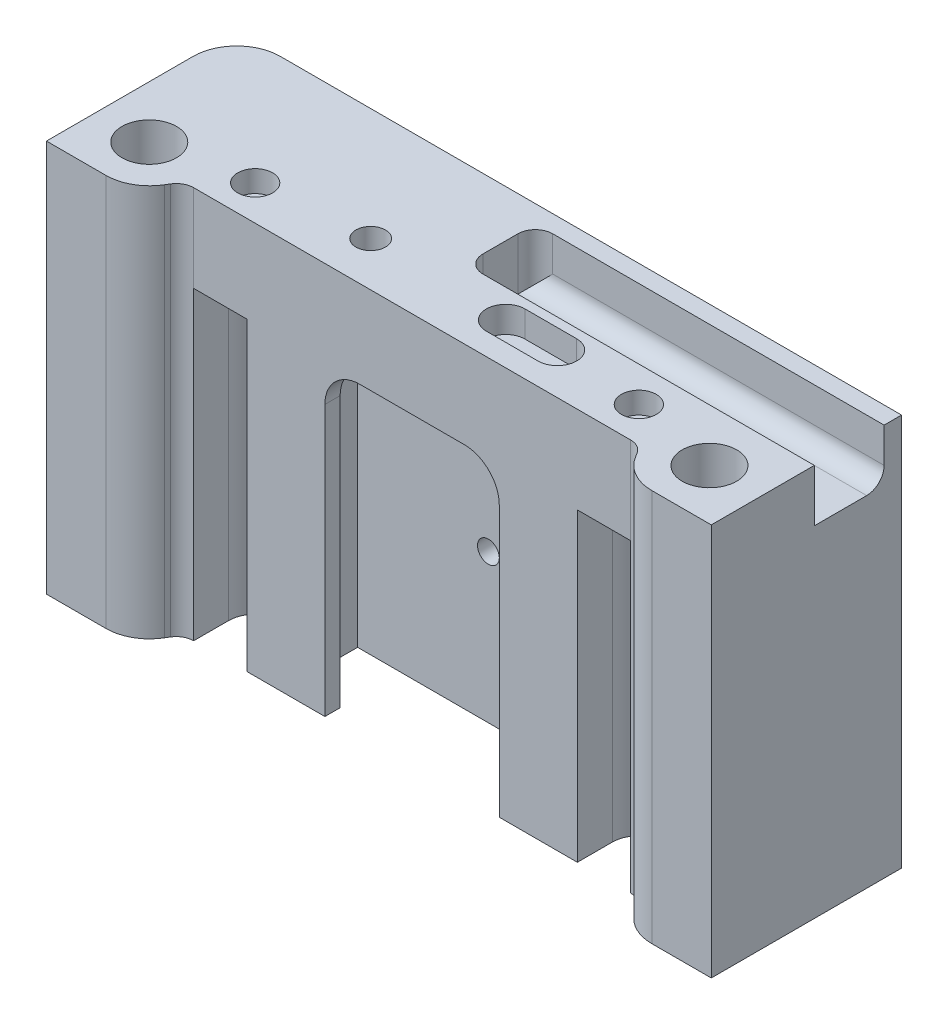
from build123d import *

# Parameters (mm, degrees)
SKETCH1_R                       = 2
SKETCH1_R_2                     = 3.125
SKETCH1_R_3                     = 1.7
BOSS_EXTRUDE1_DEPTH             = 10
FILLET2_R                       = 5
FILLET1_R                       = 2
SKETCH1_4_R                     = 3.125
CUT_EXTRUDE3_DEPTH              = 5.07
SKETCH1_7_R                     = 1.7
CUT_EXTRUDE6_DEPTH              = 10
CUT_EXTRUDE5_DEPTH              = 3
SKETCH1_5_R                     = 2
CUT_EXTRUDE4_DEPTH              = 2.48
SKETCH4_R                       = 1.5
CUT_EXTRUDE7_DEPTH              = 10
SKETCH5_R                       = 2.725
CUT_EXTRUDE8_DEPTH              = 2.8
BOSS_EXTRUDE2_DEPTH             = 10
BOSS_EXTRUDE3_DEPTH             = 35
FILLET13_R                      = 5
SKETCH10_W                      = 8
SKETCH10_H                      = 6
CUT_EXTRUDE12_DEPTH             = 40
FILLET14_R                      = 2
CUT_EXTRUDE17_DEPTH             = 35
TAP_DRILL_FOR_M3X0_5_TAP1_D     = 2.5
TAP_DRILL_FOR_M3X0_5_TAP1_DEPTH = 4.248924226
TAP_DRILL_FOR_M3X0_5_TAP1_TIP   = 0.751075774
SKETCH23_2_R                    = 3.25
BOSS_EXTRUDE7_DEPTH             = 2
FILLET16_R                      = 4
SKETCH23_R                      = 3.25
CUT_EXTRUDE20_DEPTH             = 10
CUT_EXTRUDE20_DEPTH_BACK        = 4


with BuildPart() as part:
    # Sketch1 → Boss-Extrude1 (new body)
    with BuildSketch(Plane(origin=(0, 0, 0), x_dir=(1, 0, 0), z_dir=(0, 1, 0))):
        with BuildLine():
            ThreePointArc((-11.409245094, 8.977987014), (-9.849239736, 9.28), (-8.289234378, 8.977987014))
            ThreePointArc((-8.289234378, 8.977987014), (-5.835653376, 8.254222737), (-3.289234378, 8.01))
            Line((-3.289234378, 8.01), (38.12, 8.01))
            Line((38.12, 8.01), (38.12, -3.81))
            Line((38.12, -3.81), (28.478275237, -3.81))
            Line((28.478275237, -3.81), (26.178275237, 0))
            Line((26.178275237, 0), (-26.178275237, 0))
            Line((-26.178275237, 0), (-28.478275237, -3.81))
            Line((-28.478275237, -3.81), (-38.12, -3.81))
            Line((-38.12, -3.81), (-38.12, 8.01))
            Line((-38.12, 8.01), (-16.409245094, 8.01))
            ThreePointArc((-16.409245094, 8.01), (-13.862826096, 8.254222737), (-11.409245094, 8.977987014))
        make_face()
        with Locations((22, 4.005)):
            Circle(SKETCH1_R, mode=Mode.SUBTRACT)
        with Locations((-22, 4.005)):
            Circle(SKETCH1_R, mode=Mode.SUBTRACT)
        with Locations((-32.12, 1.98)):
            Circle(SKETCH1_R_2, mode=Mode.SUBTRACT)
        with Locations((32.12, 1.98)):
            Circle(SKETCH1_R_2, mode=Mode.SUBTRACT)
        with Locations((-9.849239736, 5.1)):
            Circle(SKETCH1_R_3, mode=Mode.SUBTRACT)
        with BuildLine():
            ThreePointArc((11.912105026, 2.53), (14.127105026, 4.745), (11.912105026, 6.96))
            Line((11.912105026, 6.96), (5.992105026, 6.96))
            ThreePointArc((5.992105026, 6.96), (3.777105026, 4.745), (5.992105026, 2.53))
            Line((5.992105026, 2.53), (11.912105026, 2.53))
        make_face(mode=Mode.SUBTRACT)
        with Locations((-22, 4.005)):
            Circle(SKETCH1_R)
        with Locations((-9.849239736, 5.1)):
            Circle(SKETCH1_R_3)
        with Locations((-32.12, 1.98)):
            Circle(SKETCH1_R_2)
        with BuildLine():
            Line((5.992105026, 2.53), (11.912105026, 2.53))
            ThreePointArc((11.912105026, 2.53), (14.127105026, 4.745), (11.912105026, 6.96))
            Line((11.912105026, 6.96), (5.992105026, 6.96))
            ThreePointArc((5.992105026, 6.96), (3.777105026, 4.745), (5.992105026, 2.53))
        make_face()
        with Locations((22, 4.005)):
            Circle(SKETCH1_R)
        with Locations((32.12, 1.98)):
            Circle(SKETCH1_R_2)
    extrude(amount=-BOSS_EXTRUDE1_DEPTH)

    # Fillet2
    fillet2_edges = [part.edges().sort_by_distance(p)[0] for p in [
        (28.478275237, -5, 3.81),
        (-28.478275237, -5, 3.81),
    ]]
    fillet(fillet2_edges, radius=FILLET2_R)

    # Fillet1
    fillet1_edges = [part.edges().sort_by_distance(p)[0] for p in [
        (26.178275237, -5, 0),
        (-26.178275237, -5, 0),
    ]]
    fillet(fillet1_edges, radius=FILLET1_R)

    # Sketch1_4 → Cut-Extrude3 (cut)
    with BuildSketch(Plane(origin=(0, 0, 0), x_dir=(1, 0, 0), z_dir=(0, 1, 0))):
        with Locations(Location((32.12, 1.98, 0), (0, 0, 270))):
            Circle(SKETCH1_4_R)
        with Locations(Location((-32.12, 1.98, 0), (0, 0, 270))):
            Circle(SKETCH1_4_R)
    extrude(amount=-CUT_EXTRUDE3_DEPTH, mode=Mode.SUBTRACT)

    # Sketch1_7 → Cut-Extrude6 (cut)
    with BuildSketch(Plane(origin=(0, 0, 0), x_dir=(1, 0, 0), z_dir=(0, 1, 0))):
        with Locations(Location((-9.849239736, 5.1, 0), (0, 0, 270))):
            Circle(SKETCH1_7_R)
    extrude(amount=-CUT_EXTRUDE6_DEPTH, mode=Mode.SUBTRACT)

    # Sketch1_6 → Cut-Extrude5 (cut)
    with BuildSketch(Plane(origin=(0, 0, 0), x_dir=(1, 0, 0), z_dir=(0, 1, 0))):
        with BuildLine():
            Line((5.992105026, 2.53), (11.912105026, 2.53))
            ThreePointArc((11.912105026, 2.53), (14.127105026, 4.745), (11.912105026, 6.96))
            Line((11.912105026, 6.96), (5.992105026, 6.96))
            ThreePointArc((5.992105026, 6.96), (3.777105026, 4.745), (5.992105026, 2.53))
        make_face()
    extrude(amount=-CUT_EXTRUDE5_DEPTH, mode=Mode.SUBTRACT)

    # Sketch1_5 → Cut-Extrude4 (cut)
    with BuildSketch(Plane(origin=(0, 0, 0), x_dir=(1, 0, 0), z_dir=(0, 1, 0))):
        with Locations(Location((-22, 4.005, 0), (0, 0, 270))):
            Circle(SKETCH1_5_R)
        with Locations(Location((22, 4.005, 0), (0, 0, 270))):
            Circle(SKETCH1_5_R)
    extrude(amount=-CUT_EXTRUDE4_DEPTH, mode=Mode.SUBTRACT)

    # Sketch4 → Cut-Extrude7 (cut)
    with BuildSketch(Plane(origin=(0, 0, 0), x_dir=(1, 0, 0), z_dir=(0, 1, 0))):
        with Locations(Location((-22, 4.005, 0), (0, 0, 270))):
            Circle(SKETCH4_R)
        with Locations(Location((22, 4.005, 0), (0, 0, 270))):
            Circle(SKETCH4_R)
    extrude(amount=-CUT_EXTRUDE7_DEPTH, mode=Mode.SUBTRACT)

    # Sketch5 → Cut-Extrude8 (cut)
    with BuildSketch(Plane.XZ.offset(10)):
        with Locations(Location((22, -4.005, 0), (0, 0, 270))):
            Circle(SKETCH5_R)
        with Locations(Location((-22, -4.005, 0), (0, 0, 90))):
            Circle(SKETCH5_R)
    extrude(amount=-CUT_EXTRUDE8_DEPTH, mode=Mode.SUBTRACT)

    # Sketch6 → Boss-Extrude2 (add)
    with BuildSketch(Plane(origin=(0, 0, 0), x_dir=(1, 0, 0), z_dir=(0, 1, 0))):
        with BuildLine():
            Line((-38.12, 8.01), (-38.12, 18.01))
            Line((-38.12, 18.01), (38.12, 18.01))
            Line((38.12, 18.01), (38.12, 8.01))
            Line((38.12, 8.01), (-3.289234378, 8.01))
            ThreePointArc((-3.289234378, 8.01), (-5.835653376, 8.254222737), (-8.289234378, 8.977987014))
            ThreePointArc((-8.289234378, 8.977987014), (-9.849239736, 9.28), (-11.409245094, 8.977987014))
            ThreePointArc((-11.409245094, 8.977987014), (-13.862826096, 8.254222737), (-16.409245094, 8.01))
            Line((-16.409245094, 8.01), (-38.12, 8.01))
        make_face()
    extrude(amount=-BOSS_EXTRUDE2_DEPTH)

    # Sketch8 → Boss-Extrude3 (add)
    with BuildSketch(Plane.XZ.offset(10)):
        with BuildLine():
            Line((18.950546011, 0), (-18.950546011, 0))
            Line((-18.950546011, 0), (-18.950546011, -4.005))
            ThreePointArc((-18.950546011, -4.005), (-22, -7.054453989), (-25.049453989, -4.005))
            Line((-25.049453989, -4.005), (-25.049453989, 0))
            ThreePointArc((-25.049453989, 0), (-26.032503369, 0.25827272), (-26.761657912, 0.966386084))
            Line((-26.761657912, 0.966386084), (-27.019818549, 1.394034791))
            ThreePointArc((-27.019818549, 1.394034791), (-28.842704905, 3.164318199), (-31.300328355, 3.81))
            Line((-31.300328355, 3.81), (-38.12, 3.81))
            Line((-38.12, 3.81), (-38.12, -18.01))
            Line((-38.12, -18.01), (38.12, -18.01))
            Line((38.12, -18.01), (38.12, 3.81))
            Line((38.12, 3.81), (31.300328355, 3.81))
            ThreePointArc((31.300328355, 3.81), (28.842704905, 3.164318199), (27.019818549, 1.394034791))
            Line((27.019818549, 1.394034791), (26.761657912, 0.966386084))
            ThreePointArc((26.761657912, 0.966386084), (26.032503369, 0.25827272), (25.049453989, 0))
            Line((25.049453989, 0), (25.049453989, -4.005))
            ThreePointArc((25.049453989, -4.005), (22, -7.054453989), (18.950546011, -4.005))
            Line((18.950546011, -4.005), (18.950546011, 0))
        make_face()
    extrude(amount=BOSS_EXTRUDE3_DEPTH)

    # Fillet13
    fillet13_edges = [part.edges().sort_by_distance(p)[0] for p in [
        (-38.12, -22.5, -18.01),
    ]]
    fillet(fillet13_edges, radius=FILLET13_R)

    # Sketch10 → Cut-Extrude12 (cut)
    with BuildSketch(Plane(origin=(38.12, 0, 0), x_dir=(0, 0, -1), z_dir=(1, 0, 0))):
        with Locations((12.01, -3)):
            Rectangle(SKETCH10_W, SKETCH10_H)
    extrude(amount=-CUT_EXTRUDE12_DEPTH, mode=Mode.SUBTRACT)

    # Fillet14
    fillet14_edges = [part.edges().sort_by_distance(p)[0] for p in [
        (-1.88, -3, -16.01),
        (18.12, -6, -16.01),
        (-1.88, -3, -8.01),
    ]]
    fillet(fillet14_edges, radius=FILLET14_R)

    # Sketch18 → Cut-Extrude17 (cut)
    with BuildSketch(Plane.XZ.offset(45)):
        Polygon((-10, 0), (-10, -1.75), (-15, -1.75), (-15, -8.75), (15, -8.75), (15, -1.75), (10, -1.75), (10, 0), align=None)
    extrude(amount=-CUT_EXTRUDE17_DEPTH, mode=Mode.SUBTRACT)

    # Tap Drill for M3x0.5 Tap1
    with Locations(Plane.XY.offset(-8.75)):
        with Locations((0, -28), (0, -18)):
            Hole(TAP_DRILL_FOR_M3X0_5_TAP1_D / 2, depth=TAP_DRILL_FOR_M3X0_5_TAP1_DEPTH)
            with Locations((0, 0, -(TAP_DRILL_FOR_M3X0_5_TAP1_DEPTH + TAP_DRILL_FOR_M3X0_5_TAP1_TIP / 2))):  # 118° drill point
                Cone(0, TAP_DRILL_FOR_M3X0_5_TAP1_D / 2, TAP_DRILL_FOR_M3X0_5_TAP1_TIP, mode=Mode.SUBTRACT)

    # Sketch23_2 → Boss-Extrude7 (add)
    with BuildSketch(Plane.XZ.offset(10)):
        with Locations((-9.849239736, -5.1)):
            Circle(SKETCH23_2_R)
    extrude(amount=-BOSS_EXTRUDE7_DEPTH)

    # Fillet16
    fillet16_edges = [part.edges().sort_by_distance(p)[0] for p in [
        (-10, -10, -0.875),
        (-15, -10, -5.25),
        (15, -10, -5.25),
        (10, -10, -0.875),
    ]]
    fillet(fillet16_edges, radius=FILLET16_R)

    # Sketch23 → Cut-Extrude20 (cut, two sides)
    with BuildSketch(Plane.XZ.offset(10)) as cut_extrude20_sk:
        with Locations(Location((-9.849239736, -5.1, 0), (0, 0, 110.737075226))):
            Circle(SKETCH23_R)
    extrude(amount=CUT_EXTRUDE20_DEPTH, mode=Mode.SUBTRACT)
    extrude(cut_extrude20_sk.sketch, amount=-CUT_EXTRUDE20_DEPTH_BACK, mode=Mode.SUBTRACT)


solid = part.part
